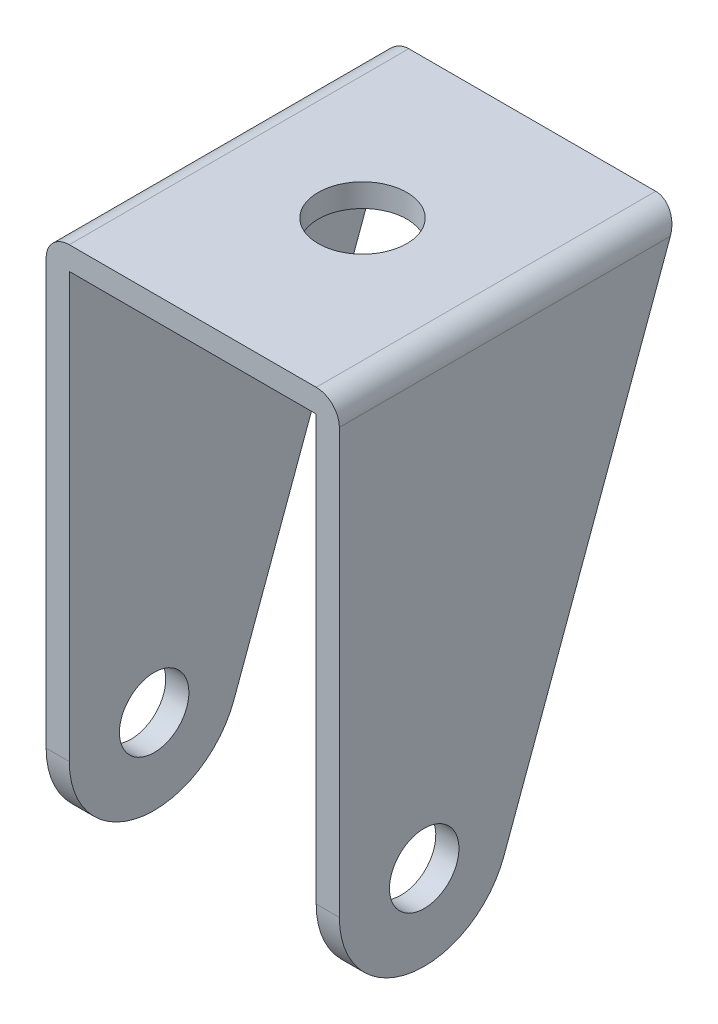
from build123d import *

# Parameters (mm, degrees)
BOSS_EXTRUDE1_DEPTH = 19
SKETCH2_W           = 32
SKETCH2_H           = 55
CUT_EXTRUDE1_DEPTH  = 45
SKETCH3_W           = 32
SKETCH3_H           = 22.717187721
CUT_EXTRUDE2_DEPTH  = 12
SKETCH4_R           = 4.5
CUT_EXTRUDE3_DEPTH  = 39
CUT_EXTRUDE4_REACH  = 71
SKETCH5_R           = 5.75
FILLET1_R           = 3


with BuildPart() as part:
    # Sketch1 → Boss-Extrude1 (new body, symmetric)
    with BuildSketch(Plane(origin=(0, 0, 0), x_dir=(0, 0, -1), z_dir=(1, 0, 0))):
        with BuildLine():
            Line((-11, 0), (-11, 58))
            Line((-11, 58), (33, 58))
            Line((33, 58), (10.326710033, -3.789335019))
            ThreePointArc((10.326710033, -3.789335019), (-1.924342697, -10.830369577), (-11, 0))
        make_face()
    extrude(amount=BOSS_EXTRUDE1_DEPTH, both=True)

    # Sketch2 → Cut-Extrude1 (cut, through all)
    with BuildSketch(Plane.XY.offset(11)):
        with Locations((0, 27.5)):
            Rectangle(SKETCH2_W, SKETCH2_H)
    extrude(amount=-CUT_EXTRUDE1_DEPTH, mode=Mode.SUBTRACT)

    # Sketch3 → Cut-Extrude2 (cut, through all)
    with BuildSketch(Plane(origin=(0, 0, 0), x_dir=(1, 0, 0), z_dir=(0, 1, 0))):
        with Locations((0, 0.358593861)):
            Rectangle(SKETCH3_W, SKETCH3_H)
    extrude(amount=-CUT_EXTRUDE2_DEPTH, mode=Mode.SUBTRACT)

    # Sketch4 → Cut-Extrude3 (cut, through all)
    with BuildSketch(Plane.ZY.offset(19)):
        Circle(SKETCH4_R)
    extrude(amount=-CUT_EXTRUDE3_DEPTH, mode=Mode.SUBTRACT)

    # Sketch5 → Cut-Extrude4 (cut, up to next)
    with BuildSketch(Plane(origin=(0, 58, 0), x_dir=(1, 0, 0), z_dir=(0, 1, 0)), mode=Mode.PRIVATE) as cut_extrude4_sk1:
        with Locations((0, 11)):
            Circle(SKETCH5_R)
    cut_extrude4_tool1 = extrude(cut_extrude4_sk1.sketch, amount=-CUT_EXTRUDE4_REACH, mode=Mode.PRIVATE) & part.part
    add(cut_extrude4_tool1.solids().sort_by_distance((0, 58, -11))[0], mode=Mode.SUBTRACT)

    # Fillet1
    fillet1_edges = [part.edges().sort_by_distance(p)[0] for p in [
        (19, 58, -11),
        (-19, 58, -11),
    ]]
    fillet(fillet1_edges, radius=FILLET1_R)


solid = part.part
